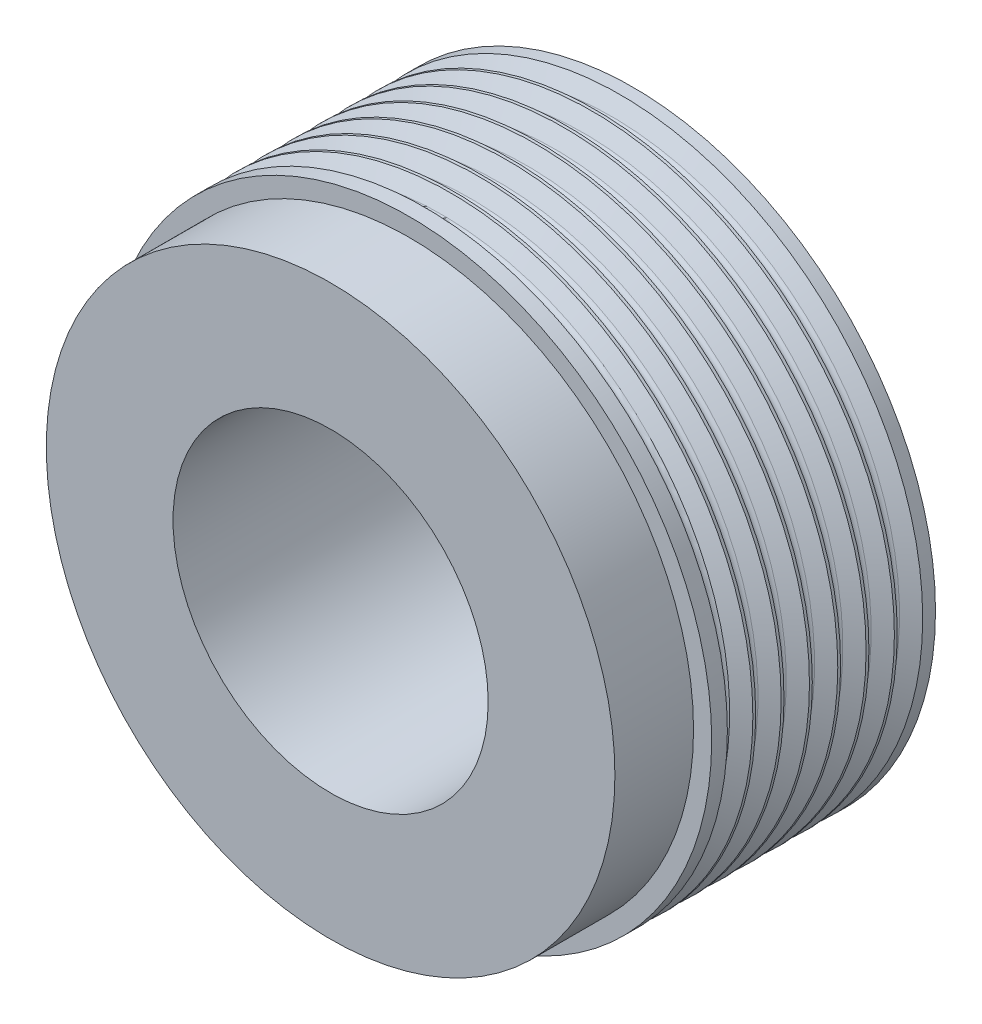
from build123d import *

# Parameters (mm, degrees)
SKETCH_1_R          = 25
EXTRUDE_1_DEPTH     = 25
SKETCH_2_R          = 25
SKETCH_2_R_2        = 23.5
CUT_EXTRUDE_1_DEPTH = 6.5
SKETCH_3_R          = 13.025
CUT_EXTRUDE_2_DEPTH = 25


with BuildPart() as part:
    # 草图1 → 凸台-拉伸1 (new body)
    with BuildSketch(Plane.XY):
        Circle(SKETCH_1_R)
    extrude(amount=EXTRUDE_1_DEPTH)

    # 草图2 → 切除-拉伸1 (cut)
    with BuildSketch(Plane.XY.offset(25)):
        Circle(SKETCH_2_R)
        Circle(SKETCH_2_R_2, mode=Mode.SUBTRACT)
    extrude(amount=-CUT_EXTRUDE_1_DEPTH, mode=Mode.SUBTRACT)

    # 草图3 → 切除-拉伸2 (cut)
    with BuildSketch(Plane.XY.offset(25)):
        Circle(SKETCH_3_R)
    extrude(amount=-CUT_EXTRUDE_2_DEPTH, mode=Mode.SUBTRACT)

    # 草图4 → 切除-旋转2 (revolve, cut)
    with BuildSketch(Plane(origin=(0, 0, 0), x_dir=(0, 0, -1), z_dir=(1, 0, 0))):
        with BuildLine():
            Line((-3.223, 25.1), (-1, 25.1))
            Line((-1, 25.1), (-1.766239155, 23.790189479))
            ThreePointArc((-1.766239155, 23.790189479), (-2.1115, 23.592167074), (-2.456760845, 23.790189479))
            Line((-2.456760845, 23.790189479), (-3.223, 25.1))
        make_face()
        with BuildLine():
            Line((-5.563, 25.1), (-3.34, 25.1))
            Line((-3.34, 25.1), (-4.106239155, 23.790189479))
            ThreePointArc((-4.106239155, 23.790189479), (-4.4515, 23.592167074), (-4.796760845, 23.790189479))
            Line((-4.796760845, 23.790189479), (-5.563, 25.1))
        make_face()
        with BuildLine():
            Line((-7.903, 25.1), (-5.68, 25.1))
            Line((-5.68, 25.1), (-6.446239155, 23.790189479))
            ThreePointArc((-6.446239155, 23.790189479), (-6.7915, 23.592167074), (-7.136760845, 23.790189479))
            Line((-7.136760845, 23.790189479), (-7.903, 25.1))
        make_face()
        with BuildLine():
            Line((-10.243, 25.1), (-8.02, 25.1))
            Line((-8.02, 25.1), (-8.786239155, 23.790189479))
            ThreePointArc((-8.786239155, 23.790189479), (-9.1315, 23.592167074), (-9.476760845, 23.790189479))
            Line((-9.476760845, 23.790189479), (-10.243, 25.1))
        make_face()
        with BuildLine():
            Line((-12.583, 25.1), (-10.36, 25.1))
            Line((-10.36, 25.1), (-11.126239155, 23.790189479))
            ThreePointArc((-11.126239155, 23.790189479), (-11.4715, 23.592167074), (-11.816760845, 23.790189479))
            Line((-11.816760845, 23.790189479), (-12.583, 25.1))
        make_face()
        with BuildLine():
            Line((-14.923, 25.1), (-12.7, 25.1))
            Line((-12.7, 25.1), (-13.466239155, 23.790189479))
            ThreePointArc((-13.466239155, 23.790189479), (-13.8115, 23.592167074), (-14.156760845, 23.790189479))
            Line((-14.156760845, 23.790189479), (-14.923, 25.1))
        make_face()
        with BuildLine():
            Line((-17.263, 25.1), (-15.04, 25.1))
            Line((-15.04, 25.1), (-15.806239155, 23.790189479))
            ThreePointArc((-15.806239155, 23.790189479), (-16.1515, 23.592167074), (-16.496760845, 23.790189479))
            Line((-16.496760845, 23.790189479), (-17.263, 25.1))
        make_face()
    revolve(axis=Axis((0, 0, 0), (0, 0, 1)), mode=Mode.SUBTRACT)


solid = part.part
